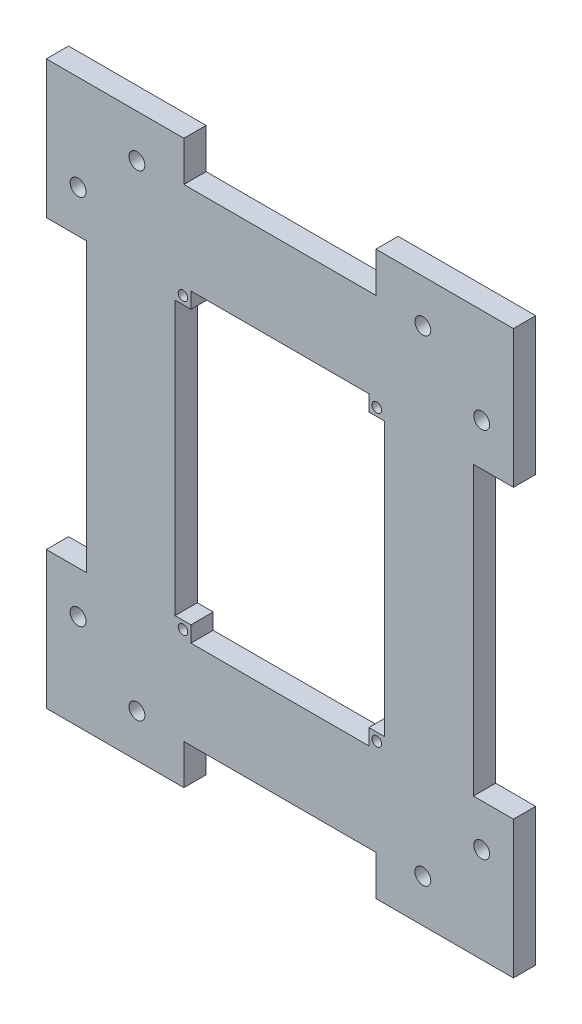
from build123d import *

# Parameters (mm, degrees)
BOSS_EXTRUDE1_DEPTH     = 7
SKETCH2_R               = 1.5
CUT_EXTRUDE1_DEPTH      = 10
MIRROR2_COPY_1_SKETCH_R = 1.5
MIRROR2_COPY_1_DEPTH    = 10
CUT_EXTRUDE4_START      = -8
SKETCH5_R               = 2.5
CUT_EXTRUDE4_DEPTH      = 9
MIRROR6_START           = -8
MIRROR6_COPY_1_SKETCH_R = 2.5
MIRROR6_COPY_1_DEPTH    = 9
CUT_EXTRUDE5_START      = -8
SKETCH6_R               = 2.5
CUT_EXTRUDE5_DEPTH      = 9
MIRROR9_START           = -8
MIRROR9_COPY_1_SKETCH_R = 2.5
MIRROR9_COPY_1_DEPTH    = 9


with BuildPart() as part:
    # Sketch1 → Boss-Extrude1 (new body)
    with BuildSketch(Plane.XY):
        Polygon((-30.22420519, 75.913209403), (30.22420519, 75.913209403), (30.22420519, 88.519824063), (73.519824063, 88.519824063), (73.519824063, 45.22420519), (60.913209403, 45.22420519), (60.913209403, -45.22420519), (73.519824063, -45.22420519), (73.519824063, -88.519824063), (30.22420519, -88.519824063), (30.22420519, -75.913209403), (-30.22420519, -75.913209403), (-30.22420519, -88.519824063), (-73.519824063, -88.519824063), (-73.519824063, -45.22420519), (-60.913209403, -45.22420519), (-60.913209403, 45.22420519), (-73.519824063, 45.22420519), (-73.519824063, 88.519824063), (-30.22420519, 88.519824063), align=None)
        Polygon((-28, 48), (28, 48), (28, 43), (33, 43), (33, -43), (28, -43), (28, -48), (-28, -48), (-28, -43), (-33, -43), (-33, 43), (-28, 43), align=None, mode=Mode.SUBTRACT)
    extrude(amount=BOSS_EXTRUDE1_DEPTH)

    # Sketch2 → Cut-Extrude1 (cut)
    with BuildSketch(Plane.XY.offset(7)):
        with Locations((30.5, -45.5)):
            Circle(SKETCH2_R)
    cut_extrude1 = extrude(amount=-CUT_EXTRUDE1_DEPTH, mode=Mode.SUBTRACT)

    # Mirror1: Cut-Extrude1 across plane
    add(cut_extrude1.mirror(Plane(origin=(0, 0, 0), x_dir=(0, 0, 1), z_dir=(1, 0, 0))), mode=Mode.SUBTRACT)

    # Mirror2: Cut-Extrude1 across plane
    add(cut_extrude1.mirror(Plane.ZX), mode=Mode.SUBTRACT)

    # Mirror2 copy 1 sketch → Mirror2 copy 1 (cut)
    with BuildSketch(Plane(origin=(0, 0, 7), x_dir=(-1, 0, 0), z_dir=(0, 0, 1))):
        with Locations((30.5, -45.5)):
            Circle(MIRROR2_COPY_1_SKETCH_R)
    extrude(amount=-MIRROR2_COPY_1_DEPTH, mode=Mode.SUBTRACT)

    # Sketch5 → Cut-Extrude4 (cut)
    with BuildSketch(Plane.XY.offset(7).offset(CUT_EXTRUDE4_START)):
        with Locations((-45, 75)):
            Circle(SKETCH5_R)
    cut_extrude4 = extrude(amount=CUT_EXTRUDE4_DEPTH, mode=Mode.SUBTRACT)

    # Mirror5: Cut-Extrude4 across plane
    add(cut_extrude4.mirror(Plane.ZX), mode=Mode.SUBTRACT)

    # Mirror6: Cut-Extrude4 across plane
    add(cut_extrude4.mirror(Plane(origin=(0, 0, 0), x_dir=(0, 0, 1), z_dir=(1, 0, 0))), mode=Mode.SUBTRACT)

    # Mirror6 copy 1 sketch → Mirror6 copy 1 (cut)
    with BuildSketch(Plane(origin=(0, 0, 7), x_dir=(-1, 0, 0), z_dir=(0, 0, 1)).offset(MIRROR6_START)):
        with Locations((-45, 75)):
            Circle(MIRROR6_COPY_1_SKETCH_R)
    extrude(amount=MIRROR6_COPY_1_DEPTH, mode=Mode.SUBTRACT)

    # Sketch6 → Cut-Extrude5 (cut)
    with BuildSketch(Plane(origin=(0, 0, 0), x_dir=(-1, 0, 0), z_dir=(0, 0, -1)).offset(CUT_EXTRUDE5_START)):
        with Locations((63.519824063, 58.519824063)):
            Circle(SKETCH6_R)
    cut_extrude5 = extrude(amount=CUT_EXTRUDE5_DEPTH, mode=Mode.SUBTRACT)

    # Mirror8: Cut-Extrude5 across plane
    add(cut_extrude5.mirror(Plane(origin=(0, 0, 0), x_dir=(0, 0, 1), z_dir=(1, 0, 0))), mode=Mode.SUBTRACT)

    # Mirror9: Cut-Extrude5 across plane
    add(cut_extrude5.mirror(Plane.ZX), mode=Mode.SUBTRACT)

    # Mirror9 copy 1 sketch → Mirror9 copy 1 (cut)
    with BuildSketch(Plane(origin=(0, 0, 0), x_dir=(1, 0, 0), z_dir=(0, 0, -1)).offset(MIRROR9_START)):
        with Locations((63.519824063, 58.519824063)):
            Circle(MIRROR9_COPY_1_SKETCH_R)
    extrude(amount=MIRROR9_COPY_1_DEPTH, mode=Mode.SUBTRACT)


solid = part.part
